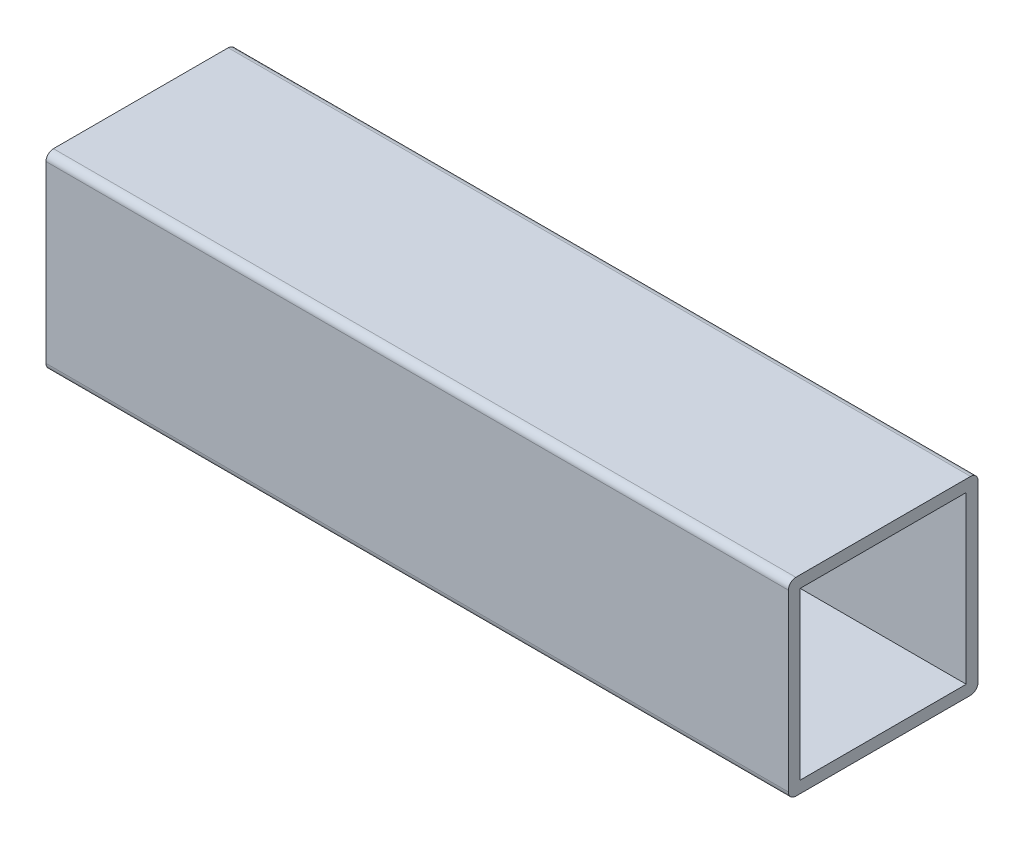
from build123d import *

# Parameters (mm, degrees)
SKETCH2_W                = 25.54
SKETCH2_H                = 25.54
SKETCH2_W_2              = 22.365
SKETCH2_H_2              = 22.365
BOSS_EXTRUDE1_DEPTH      = 50
BOSS_EXTRUDE1_DEPTH_BACK = 50
FILLET1_R                = 1


with BuildPart() as part:
    # Sketch2 → Boss-Extrude1 (new body, two sides)
    with BuildSketch(Plane(origin=(0, 0, 0), x_dir=(0, 0, -1), z_dir=(1, 0, 0))) as boss_extrude1_sk:
        Rectangle(SKETCH2_W, SKETCH2_H)
        Rectangle(SKETCH2_W_2, SKETCH2_H_2, mode=Mode.SUBTRACT)
    extrude(amount=BOSS_EXTRUDE1_DEPTH)
    extrude(boss_extrude1_sk.sketch, amount=-BOSS_EXTRUDE1_DEPTH_BACK)

    # Fillet1
    fillet1_edges = [part.edges().sort_by_distance(p)[0] for p in [
        (0, -12.77, -12.77),
        (0, -12.77, 12.77),
        (0, 12.77, 12.77),
        (0, 12.77, -12.77),
    ]]
    fillet(fillet1_edges, radius=FILLET1_R)


solid = part.part
